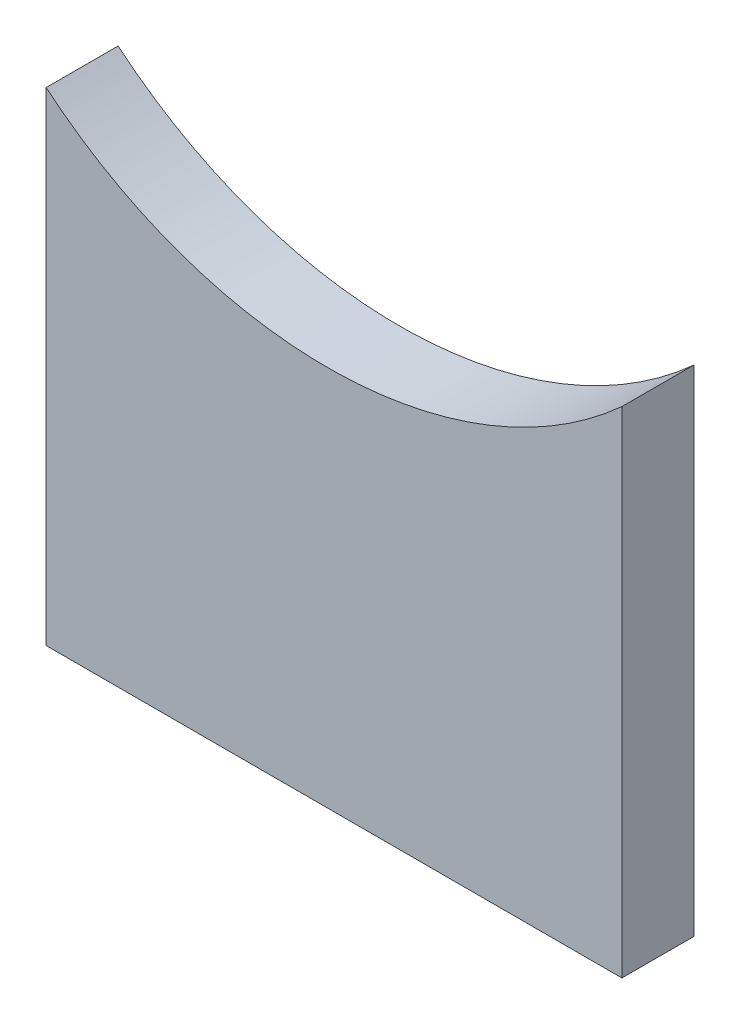
from build123d import *

# Parameters (mm, degrees)
SZKIC1_W                    = 16
SZKIC1_H                    = 31.855734842
DODANIE_WYCI_GNI_CIE1_DEPTH = 2
SZKIC2_W                    = 16
SZKIC2_H                    = 5
WYTNIJ_WYCI_GNI_CIE1_DEPTH  = 5
WYTNIJ_WYCI_GNI_CIE2_DEPTH  = 10


with BuildPart() as part:
    # Szkic1 → Dodanie-wyciągnięcie1 (new body)
    with BuildSketch(Plane.XY):
        with Locations((8, 15.927867421)):
            Rectangle(SZKIC1_W, SZKIC1_H)
    extrude(amount=DODANIE_WYCI_GNI_CIE1_DEPTH)

    # Szkic2 → Wytnij-wyciągnięcie1 (cut)
    with BuildSketch(Plane.XY.offset(2)):
        with Locations((8, 2.5)):
            Rectangle(SZKIC2_W, SZKIC2_H)
    extrude(amount=-WYTNIJ_WYCI_GNI_CIE1_DEPTH, mode=Mode.SUBTRACT)

    # Szkic6 → Wytnij-wyciągnięcie2 (cut)
    with BuildSketch(Plane(origin=(0, 0, 0), x_dir=(-1, 0, 0), z_dir=(0, 0, -1))):
        with BuildLine():
            Line((0, 31.855734842), (-16, 31.855734842))
            Line((-16, 31.855734842), (-16, 18.750886073))
            ThreePointArc((-16, 18.750886073), (-8.06030582, 15.602264045), (0, 18.427867421))
            Line((0, 18.427867421), (0, 31.855734842))
        make_face()
    extrude(amount=-WYTNIJ_WYCI_GNI_CIE2_DEPTH, mode=Mode.SUBTRACT)


solid = part.part
